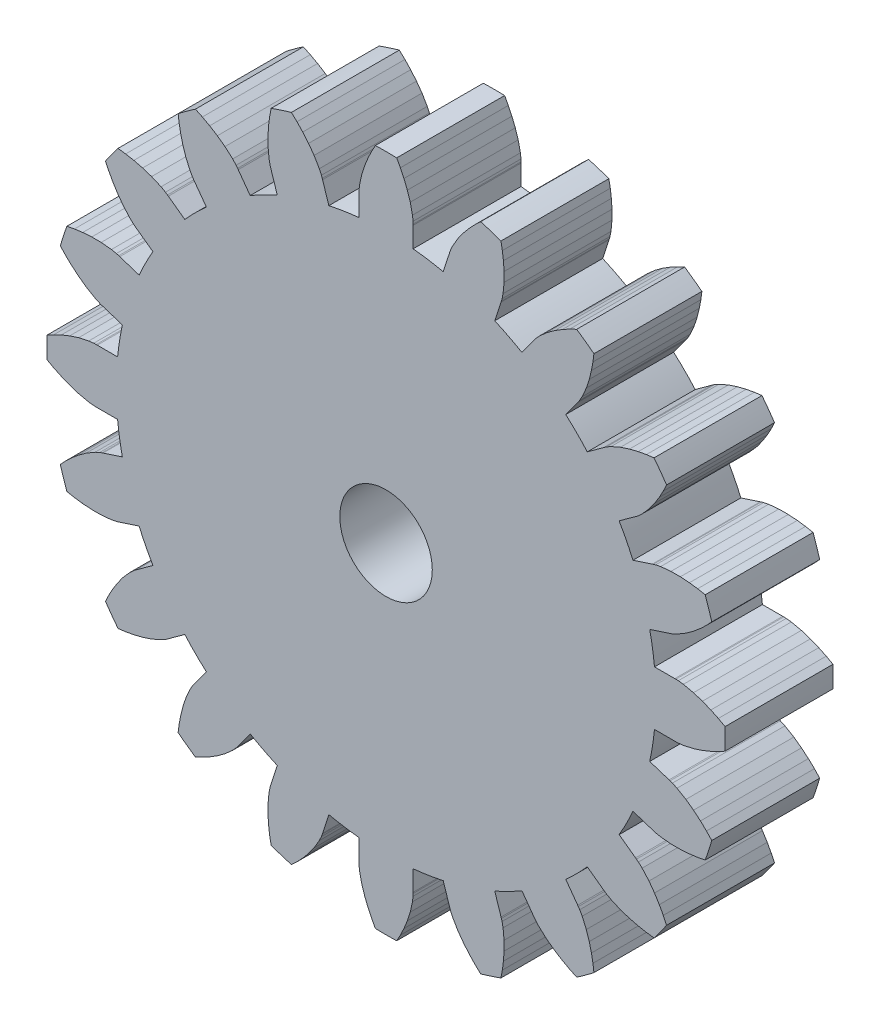
from build123d import *

# Parameters (mm, degrees)
ESQUISSE1_R        = 1.5
BOSS_EXTRU_1_DEPTH = 3.5


with BuildPart() as part:
    # Esquisse1 → Boss.-Extru.1 (new body)
    with BuildSketch(Plane.XY.offset(10)):
        with BuildLine():
            Line((10.391944356, 2.887552219), (10.563205564, 3.068988142))
            ThreePointArc((10.563205564, 3.068988142), (10.461621679, 3.399186938), (10.349718786, 3.726032885))
            Line((10.349718786, 3.726032885), (10.104520198, 3.772152817))
            Line((10.104520198, 3.772152817), (9.837219071, 3.807097852))
            Line((9.837219071, 3.807097852), (9.544179746, 3.827948471))
            Line((9.544179746, 3.827948471), (9.238485434, 3.827582381))
            Line((9.238485434, 3.827582381), (8.905478411, 3.795081802))
            Line((8.905478411, 3.795081802), (8.744253499, 3.762531781))
            Line((8.744253499, 3.762531781), (8.667570956, 3.740873836))
            Line((8.667570956, 3.740873836), (8.6348822, 3.729525456))
            Line((8.6348822, 3.729525456), (8.008304172, 3.52555872))
            ThreePointArc((8.008304172, 3.52555872), (7.796307087, 3.972416873), (7.559400007, 4.40658275))
            Line((7.559400007, 4.40658275), (8.092705887, 4.793606383))
            Line((8.092705887, 4.793606383), (8.121100889, 4.813381732))
            Line((8.121100889, 4.813381732), (8.183695402, 4.862688991))
            Line((8.183695402, 4.862688991), (8.304794548, 4.973990263))
            Line((8.304794548, 4.973990263), (8.526824685, 5.224295243))
            Line((8.526824685, 5.224295243), (8.706803467, 5.471391954))
            Line((8.706803467, 5.471391954), (8.862179155, 5.720721434))
            Line((8.862179155, 5.720721434), (8.991023689, 5.957512765))
            Line((8.991023689, 5.957512765), (9.097835993, 6.182991205))
            ThreePointArc((9.097835993, 6.182991205), (8.899186938, 6.465637775), (8.69176001, 6.741906847))
            Line((8.69176001, 6.741906847), (8.444310453, 6.709998979))
            Line((8.444310453, 6.709998979), (8.179293364, 6.660633091))
            Line((8.179293364, 6.660633091), (7.894153209, 6.589909076))
            Line((7.894153209, 6.589909076), (7.60353377, 6.495096166))
            Line((7.60353377, 6.495096166), (7.296868502, 6.36128145))
            Line((7.296868502, 6.36128145), (7.153593008, 6.280503303))
            Line((7.153593008, 6.280503303), (7.087356249, 6.236209164))
            Line((7.087356249, 6.236209164), (7.059774237, 6.215314832))
            Line((7.059774237, 6.215314832), (6.526892308, 5.82770768))
            ThreePointArc((6.526892308, 5.82770768), (6.187184335, 6.187184335), (5.82770768, 6.526892308))
            Line((5.82770768, 6.526892308), (6.215314832, 7.059774237))
            Line((6.215314832, 7.059774237), (6.236209164, 7.087356249))
            Line((6.236209164, 7.087356249), (6.280503303, 7.153593008))
            Line((6.280503303, 7.153593008), (6.36128145, 7.296868502))
            Line((6.36128145, 7.296868502), (6.495096166, 7.60353377))
            Line((6.495096166, 7.60353377), (6.589909076, 7.894153209))
            Line((6.589909076, 7.894153209), (6.660633091, 8.179293364))
            Line((6.660633091, 8.179293364), (6.709998979, 8.444310453))
            Line((6.709998979, 8.444310453), (6.741906847, 8.69176001))
            ThreePointArc((6.741906847, 8.69176001), (6.465637775, 8.899186938), (6.182991205, 9.097835993))
            Line((6.182991205, 9.097835993), (5.957512765, 8.991023689))
            Line((5.957512765, 8.991023689), (5.720721434, 8.862179155))
            Line((5.720721434, 8.862179155), (5.471391954, 8.706803467))
            Line((5.471391954, 8.706803467), (5.224295243, 8.526824685))
            Line((5.224295243, 8.526824685), (4.973990263, 8.304794548))
            Line((4.973990263, 8.304794548), (4.862688991, 8.183695402))
            Line((4.862688991, 8.183695402), (4.813381732, 8.121100889))
            Line((4.813381732, 8.121100889), (4.793606383, 8.092705887))
            Line((4.793606383, 8.092705887), (4.40658275, 7.559400007))
            ThreePointArc((4.40658275, 7.559400007), (3.972416873, 7.796307087), (3.52555872, 8.008304172))
            Line((3.52555872, 8.008304172), (3.729525456, 8.6348822))
            Line((3.729525456, 8.6348822), (3.740873836, 8.667570956))
            Line((3.740873836, 8.667570956), (3.762531781, 8.744253499))
            Line((3.762531781, 8.744253499), (3.795081802, 8.905478411))
            Line((3.795081802, 8.905478411), (3.827582381, 9.238485434))
            Line((3.827582381, 9.238485434), (3.827948471, 9.544179746))
            Line((3.827948471, 9.544179746), (3.807097852, 9.837219071))
            Line((3.807097852, 9.837219071), (3.772152817, 10.104520198))
            Line((3.772152817, 10.104520198), (3.726032885, 10.349718786))
            ThreePointArc((3.726032885, 10.349718786), (3.399186938, 10.461621679), (3.068988142, 10.563205564))
            Line((3.068988142, 10.563205564), (2.887552219, 10.391944356))
            Line((2.887552219, 10.391944356), (2.702165432, 10.196233377))
            Line((2.702165432, 10.196233377), (2.513052733, 9.97141527))
            Line((2.513052733, 9.97141527), (2.333666298, 9.723888194))
            Line((2.333666298, 9.723888194), (2.164223202, 9.435376492))
            Line((2.164223202, 9.435376492), (2.095791096, 9.285810376))
            Line((2.095791096, 9.285810376), (2.068239874, 9.211042675))
            Line((2.068239874, 9.211042675), (2.058206937, 9.177926505))
            Line((2.058206937, 9.177926505), (1.854926169, 8.551125593))
            ThreePointArc((1.854926169, 8.551125593), (1.368801569, 8.64227298), (0.878303509, 8.705807426))
            Line((0.878303509, 8.705807426), (0.878664144, 9.364747731))
            Line((0.878664144, 9.364747731), (0.879355713, 9.399343428))
            Line((0.879355713, 9.399343428), (0.876257434, 9.478965532))
            Line((0.876257434, 9.478965532), (0.857393106, 9.642358046))
            Line((0.857393106, 9.642358046), (0.785398163, 9.969109776))
            Line((0.785398163, 9.969109776), (0.691281599, 10.259955471))
            Line((0.691281599, 10.259955471), (0.58089735, 10.532209235))
            Line((0.58089735, 10.532209235), (0.465062056, 10.775629104))
            Line((0.465062056, 10.775629104), (0.345428864, 10.994574976))
            ThreePointArc((0.345428864, 10.994574976), (0, 11), (-0.345428864, 10.994574976))
            Line((-0.345428864, 10.994574976), (-0.465062056, 10.775629104))
            Line((-0.465062056, 10.775629104), (-0.58089735, 10.532209235))
            Line((-0.58089735, 10.532209235), (-0.691281599, 10.259955471))
            Line((-0.691281599, 10.259955471), (-0.785398163, 9.969109776))
            Line((-0.785398163, 9.969109776), (-0.857393106, 9.642358046))
            Line((-0.857393106, 9.642358046), (-0.876257434, 9.478965532))
            Line((-0.876257434, 9.478965532), (-0.879355713, 9.399343428))
            Line((-0.879355713, 9.399343428), (-0.878664144, 9.364747731))
            Line((-0.878664144, 9.364747731), (-0.878303509, 8.705807426))
            ThreePointArc((-0.878303509, 8.705807426), (-1.368801569, 8.64227298), (-1.854926169, 8.551125593))
            Line((-1.854926169, 8.551125593), (-2.058206937, 9.177926505))
            Line((-2.058206937, 9.177926505), (-2.068239874, 9.211042675))
            Line((-2.068239874, 9.211042675), (-2.095791096, 9.285810376))
            Line((-2.095791096, 9.285810376), (-2.164223202, 9.435376492))
            Line((-2.164223202, 9.435376492), (-2.333666298, 9.723888194))
            Line((-2.333666298, 9.723888194), (-2.513052733, 9.97141527))
            Line((-2.513052733, 9.97141527), (-2.702165432, 10.196233377))
            Line((-2.702165432, 10.196233377), (-2.887552219, 10.391944356))
            Line((-2.887552219, 10.391944356), (-3.068988142, 10.563205564))
            ThreePointArc((-3.068988142, 10.563205564), (-3.399186938, 10.461621679), (-3.726032885, 10.349718786))
            Line((-3.726032885, 10.349718786), (-3.772152817, 10.104520198))
            Line((-3.772152817, 10.104520198), (-3.807097852, 9.837219071))
            Line((-3.807097852, 9.837219071), (-3.827948471, 9.544179746))
            Line((-3.827948471, 9.544179746), (-3.827582381, 9.238485434))
            Line((-3.827582381, 9.238485434), (-3.795081802, 8.905478411))
            Line((-3.795081802, 8.905478411), (-3.762531781, 8.744253499))
            Line((-3.762531781, 8.744253499), (-3.740873836, 8.667570956))
            Line((-3.740873836, 8.667570956), (-3.729525456, 8.6348822))
            Line((-3.729525456, 8.6348822), (-3.52555872, 8.008304172))
            ThreePointArc((-3.52555872, 8.008304172), (-3.972416873, 7.796307087), (-4.40658275, 7.559400007))
            Line((-4.40658275, 7.559400007), (-4.793606383, 8.092705887))
            Line((-4.793606383, 8.092705887), (-4.813381732, 8.121100889))
            Line((-4.813381732, 8.121100889), (-4.862688991, 8.183695402))
            Line((-4.862688991, 8.183695402), (-4.973990263, 8.304794548))
            Line((-4.973990263, 8.304794548), (-5.224295243, 8.526824685))
            Line((-5.224295243, 8.526824685), (-5.471391954, 8.706803467))
            Line((-5.471391954, 8.706803467), (-5.720721434, 8.862179155))
            Line((-5.720721434, 8.862179155), (-5.957512765, 8.991023689))
            Line((-5.957512765, 8.991023689), (-6.182991205, 9.097835993))
            ThreePointArc((-6.182991205, 9.097835993), (-6.465637775, 8.899186938), (-6.741906847, 8.69176001))
            Line((-6.741906847, 8.69176001), (-6.709998979, 8.444310453))
            Line((-6.709998979, 8.444310453), (-6.660633091, 8.179293364))
            Line((-6.660633091, 8.179293364), (-6.589909076, 7.894153209))
            Line((-6.589909076, 7.894153209), (-6.495096166, 7.60353377))
            Line((-6.495096166, 7.60353377), (-6.36128145, 7.296868502))
            Line((-6.36128145, 7.296868502), (-6.280503303, 7.153593008))
            Line((-6.280503303, 7.153593008), (-6.236209164, 7.087356249))
            Line((-6.236209164, 7.087356249), (-6.215314832, 7.059774237))
            Line((-6.215314832, 7.059774237), (-5.82770768, 6.526892308))
            ThreePointArc((-5.82770768, 6.526892308), (-6.187184335, 6.187184335), (-6.526892308, 5.82770768))
            Line((-6.526892308, 5.82770768), (-7.059774237, 6.215314832))
            Line((-7.059774237, 6.215314832), (-7.087356249, 6.236209164))
            Line((-7.087356249, 6.236209164), (-7.153593008, 6.280503303))
            Line((-7.153593008, 6.280503303), (-7.296868502, 6.36128145))
            Line((-7.296868502, 6.36128145), (-7.60353377, 6.495096166))
            Line((-7.60353377, 6.495096166), (-7.894153209, 6.589909076))
            Line((-7.894153209, 6.589909076), (-8.179293364, 6.660633091))
            Line((-8.179293364, 6.660633091), (-8.444310453, 6.709998979))
            Line((-8.444310453, 6.709998979), (-8.69176001, 6.741906847))
            ThreePointArc((-8.69176001, 6.741906847), (-8.899186938, 6.465637775), (-9.097835993, 6.182991205))
            Line((-9.097835993, 6.182991205), (-8.991023689, 5.957512765))
            Line((-8.991023689, 5.957512765), (-8.862179155, 5.720721434))
            Line((-8.862179155, 5.720721434), (-8.706803467, 5.471391954))
            Line((-8.706803467, 5.471391954), (-8.526824685, 5.224295243))
            Line((-8.526824685, 5.224295243), (-8.304794548, 4.973990263))
            Line((-8.304794548, 4.973990263), (-8.183695402, 4.862688991))
            Line((-8.183695402, 4.862688991), (-8.121100889, 4.813381732))
            Line((-8.121100889, 4.813381732), (-8.092705887, 4.793606383))
            Line((-8.092705887, 4.793606383), (-7.559400007, 4.40658275))
            ThreePointArc((-7.559400007, 4.40658275), (-7.796307087, 3.972416873), (-8.008304172, 3.52555872))
            Line((-8.008304172, 3.52555872), (-8.6348822, 3.729525456))
            Line((-8.6348822, 3.729525456), (-8.667570956, 3.740873836))
            Line((-8.667570956, 3.740873836), (-8.744253499, 3.762531781))
            Line((-8.744253499, 3.762531781), (-8.905478411, 3.795081802))
            Line((-8.905478411, 3.795081802), (-9.238485434, 3.827582381))
            Line((-9.238485434, 3.827582381), (-9.544179746, 3.827948471))
            Line((-9.544179746, 3.827948471), (-9.837219071, 3.807097852))
            Line((-9.837219071, 3.807097852), (-10.104520198, 3.772152817))
            Line((-10.104520198, 3.772152817), (-10.349718786, 3.726032885))
            ThreePointArc((-10.349718786, 3.726032885), (-10.461621679, 3.399186938), (-10.563205564, 3.068988142))
            Line((-10.563205564, 3.068988142), (-10.391944356, 2.887552219))
            Line((-10.391944356, 2.887552219), (-10.196233377, 2.702165432))
            Line((-10.196233377, 2.702165432), (-9.97141527, 2.513052733))
            Line((-9.97141527, 2.513052733), (-9.723888194, 2.333666298))
            Line((-9.723888194, 2.333666298), (-9.435376492, 2.164223202))
            Line((-9.435376492, 2.164223202), (-9.285810376, 2.095791096))
            Line((-9.285810376, 2.095791096), (-9.211042675, 2.068239874))
            Line((-9.211042675, 2.068239874), (-9.177926505, 2.058206937))
            Line((-9.177926505, 2.058206937), (-8.551125593, 1.854926169))
            ThreePointArc((-8.551125593, 1.854926169), (-8.64227298, 1.368801569), (-8.705807426, 0.878303509))
            Line((-8.705807426, 0.878303509), (-9.364747731, 0.878664144))
            Line((-9.364747731, 0.878664144), (-9.399343428, 0.879355713))
            Line((-9.399343428, 0.879355713), (-9.478965532, 0.876257434))
            Line((-9.478965532, 0.876257434), (-9.642358046, 0.857393106))
            Line((-9.642358046, 0.857393106), (-9.969109776, 0.785398163))
            Line((-9.969109776, 0.785398163), (-10.259955471, 0.691281599))
            Line((-10.259955471, 0.691281599), (-10.532209235, 0.58089735))
            Line((-10.532209235, 0.58089735), (-10.775629104, 0.465062056))
            Line((-10.775629104, 0.465062056), (-10.994574976, 0.345428864))
            ThreePointArc((-10.994574976, 0.345428864), (-11, 0), (-10.994574976, -0.345428864))
            Line((-10.994574976, -0.345428864), (-10.775629104, -0.465062056))
            Line((-10.775629104, -0.465062056), (-10.532209235, -0.58089735))
            Line((-10.532209235, -0.58089735), (-10.259955471, -0.691281599))
            Line((-10.259955471, -0.691281599), (-9.969109776, -0.785398163))
            Line((-9.969109776, -0.785398163), (-9.642358046, -0.857393106))
            Line((-9.642358046, -0.857393106), (-9.478965532, -0.876257434))
            Line((-9.478965532, -0.876257434), (-9.399343428, -0.879355713))
            Line((-9.399343428, -0.879355713), (-9.364747731, -0.878664144))
            Line((-9.364747731, -0.878664144), (-8.705807426, -0.878303509))
            ThreePointArc((-8.705807426, -0.878303509), (-8.64227298, -1.368801569), (-8.551125593, -1.854926169))
            Line((-8.551125593, -1.854926169), (-9.177926505, -2.058206937))
            Line((-9.177926505, -2.058206937), (-9.211042675, -2.068239874))
            Line((-9.211042675, -2.068239874), (-9.285810376, -2.095791096))
            Line((-9.285810376, -2.095791096), (-9.435376492, -2.164223202))
            Line((-9.435376492, -2.164223202), (-9.723888194, -2.333666298))
            Line((-9.723888194, -2.333666298), (-9.97141527, -2.513052733))
            Line((-9.97141527, -2.513052733), (-10.196233377, -2.702165432))
            Line((-10.196233377, -2.702165432), (-10.391944356, -2.887552219))
            Line((-10.391944356, -2.887552219), (-10.563205564, -3.068988142))
            ThreePointArc((-10.563205564, -3.068988142), (-10.461621679, -3.399186938), (-10.349718786, -3.726032885))
            Line((-10.349718786, -3.726032885), (-10.104520198, -3.772152817))
            Line((-10.104520198, -3.772152817), (-9.837219071, -3.807097852))
            Line((-9.837219071, -3.807097852), (-9.544179746, -3.827948471))
            Line((-9.544179746, -3.827948471), (-9.238485434, -3.827582381))
            Line((-9.238485434, -3.827582381), (-8.905478411, -3.795081802))
            Line((-8.905478411, -3.795081802), (-8.744253499, -3.762531781))
            Line((-8.744253499, -3.762531781), (-8.667570956, -3.740873836))
            Line((-8.667570956, -3.740873836), (-8.6348822, -3.729525456))
            Line((-8.6348822, -3.729525456), (-8.008304172, -3.52555872))
            ThreePointArc((-8.008304172, -3.52555872), (-7.796307087, -3.972416873), (-7.559400007, -4.40658275))
            Line((-7.559400007, -4.40658275), (-8.092705887, -4.793606383))
            Line((-8.092705887, -4.793606383), (-8.121100889, -4.813381732))
            Line((-8.121100889, -4.813381732), (-8.183695402, -4.862688991))
            Line((-8.183695402, -4.862688991), (-8.304794548, -4.973990263))
            Line((-8.304794548, -4.973990263), (-8.526824685, -5.224295243))
            Line((-8.526824685, -5.224295243), (-8.706803467, -5.471391954))
            Line((-8.706803467, -5.471391954), (-8.862179155, -5.720721434))
            Line((-8.862179155, -5.720721434), (-8.991023689, -5.957512765))
            Line((-8.991023689, -5.957512765), (-9.097835993, -6.182991205))
            ThreePointArc((-9.097835993, -6.182991205), (-8.899186938, -6.465637775), (-8.69176001, -6.741906847))
            Line((-8.69176001, -6.741906847), (-8.444310453, -6.709998979))
            Line((-8.444310453, -6.709998979), (-8.179293364, -6.660633091))
            Line((-8.179293364, -6.660633091), (-7.894153209, -6.589909076))
            Line((-7.894153209, -6.589909076), (-7.60353377, -6.495096166))
            Line((-7.60353377, -6.495096166), (-7.296868502, -6.36128145))
            Line((-7.296868502, -6.36128145), (-7.153593008, -6.280503303))
            Line((-7.153593008, -6.280503303), (-7.087356249, -6.236209164))
            Line((-7.087356249, -6.236209164), (-7.059774237, -6.215314832))
            Line((-7.059774237, -6.215314832), (-6.526892308, -5.82770768))
            ThreePointArc((-6.526892308, -5.82770768), (-6.187184335, -6.187184335), (-5.82770768, -6.526892308))
            Line((-5.82770768, -6.526892308), (-6.215314832, -7.059774237))
            Line((-6.215314832, -7.059774237), (-6.236209164, -7.087356249))
            Line((-6.236209164, -7.087356249), (-6.280503303, -7.153593008))
            Line((-6.280503303, -7.153593008), (-6.36128145, -7.296868502))
            Line((-6.36128145, -7.296868502), (-6.495096166, -7.60353377))
            Line((-6.495096166, -7.60353377), (-6.589909076, -7.894153209))
            Line((-6.589909076, -7.894153209), (-6.660633091, -8.179293364))
            Line((-6.660633091, -8.179293364), (-6.709998979, -8.444310453))
            Line((-6.709998979, -8.444310453), (-6.741906847, -8.69176001))
            ThreePointArc((-6.741906847, -8.69176001), (-6.465637775, -8.899186938), (-6.182991205, -9.097835993))
            Line((-6.182991205, -9.097835993), (-5.957512765, -8.991023689))
            Line((-5.957512765, -8.991023689), (-5.720721434, -8.862179155))
            Line((-5.720721434, -8.862179155), (-5.471391954, -8.706803467))
            Line((-5.471391954, -8.706803467), (-5.224295243, -8.526824685))
            Line((-5.224295243, -8.526824685), (-4.973990263, -8.304794548))
            Line((-4.973990263, -8.304794548), (-4.862688991, -8.183695402))
            Line((-4.862688991, -8.183695402), (-4.813381732, -8.121100889))
            Line((-4.813381732, -8.121100889), (-4.793606383, -8.092705887))
            Line((-4.793606383, -8.092705887), (-4.40658275, -7.559400007))
            ThreePointArc((-4.40658275, -7.559400007), (-3.972416873, -7.796307087), (-3.52555872, -8.008304172))
            Line((-3.52555872, -8.008304172), (-3.729525456, -8.6348822))
            Line((-3.729525456, -8.6348822), (-3.740873836, -8.667570956))
            Line((-3.740873836, -8.667570956), (-3.762531781, -8.744253499))
            Line((-3.762531781, -8.744253499), (-3.795081802, -8.905478411))
            Line((-3.795081802, -8.905478411), (-3.827582381, -9.238485434))
            Line((-3.827582381, -9.238485434), (-3.827948471, -9.544179746))
            Line((-3.827948471, -9.544179746), (-3.807097852, -9.837219071))
            Line((-3.807097852, -9.837219071), (-3.772152817, -10.104520198))
            Line((-3.772152817, -10.104520198), (-3.726032885, -10.349718786))
            ThreePointArc((-3.726032885, -10.349718786), (-3.399186938, -10.461621679), (-3.068988142, -10.563205564))
            Line((-3.068988142, -10.563205564), (-2.887552219, -10.391944356))
            Line((-2.887552219, -10.391944356), (-2.702165432, -10.196233377))
            Line((-2.702165432, -10.196233377), (-2.513052733, -9.97141527))
            Line((-2.513052733, -9.97141527), (-2.333666298, -9.723888194))
            Line((-2.333666298, -9.723888194), (-2.164223202, -9.435376492))
            Line((-2.164223202, -9.435376492), (-2.095791096, -9.285810376))
            Line((-2.095791096, -9.285810376), (-2.068239874, -9.211042675))
            Line((-2.068239874, -9.211042675), (-2.058206937, -9.177926505))
            Line((-2.058206937, -9.177926505), (-1.854926169, -8.551125593))
            ThreePointArc((-1.854926169, -8.551125593), (-1.368801569, -8.64227298), (-0.878303509, -8.705807426))
            Line((-0.878303509, -8.705807426), (-0.878664144, -9.364747731))
            Line((-0.878664144, -9.364747731), (-0.879355713, -9.399343428))
            Line((-0.879355713, -9.399343428), (-0.876257434, -9.478965532))
            Line((-0.876257434, -9.478965532), (-0.857393106, -9.642358046))
            Line((-0.857393106, -9.642358046), (-0.785398163, -9.969109776))
            Line((-0.785398163, -9.969109776), (-0.691281599, -10.259955471))
            Line((-0.691281599, -10.259955471), (-0.58089735, -10.532209235))
            Line((-0.58089735, -10.532209235), (-0.465062056, -10.775629104))
            Line((-0.465062056, -10.775629104), (-0.345428864, -10.994574976))
            ThreePointArc((-0.345428864, -10.994574976), (0, -11), (0.345428864, -10.994574976))
            Line((0.345428864, -10.994574976), (0.465062056, -10.775629104))
            Line((0.465062056, -10.775629104), (0.58089735, -10.532209235))
            Line((0.58089735, -10.532209235), (0.691281599, -10.259955471))
            Line((0.691281599, -10.259955471), (0.785398163, -9.969109776))
            Line((0.785398163, -9.969109776), (0.857393106, -9.642358046))
            Line((0.857393106, -9.642358046), (0.876257434, -9.478965532))
            Line((0.876257434, -9.478965532), (0.879355713, -9.399343428))
            Line((0.879355713, -9.399343428), (0.878664144, -9.364747731))
            Line((0.878664144, -9.364747731), (0.878303509, -8.705807426))
            ThreePointArc((0.878303509, -8.705807426), (1.368801569, -8.64227298), (1.854926169, -8.551125593))
            Line((1.854926169, -8.551125593), (2.058206937, -9.177926505))
            Line((2.058206937, -9.177926505), (2.068239874, -9.211042675))
            Line((2.068239874, -9.211042675), (2.095791096, -9.285810376))
            Line((2.095791096, -9.285810376), (2.164223202, -9.435376492))
            Line((2.164223202, -9.435376492), (2.333666298, -9.723888194))
            Line((2.333666298, -9.723888194), (2.513052733, -9.97141527))
            Line((2.513052733, -9.97141527), (2.702165432, -10.196233377))
            Line((2.702165432, -10.196233377), (2.887552219, -10.391944356))
            Line((2.887552219, -10.391944356), (3.068988142, -10.563205564))
            ThreePointArc((3.068988142, -10.563205564), (3.399186938, -10.461621679), (3.726032885, -10.349718786))
            Line((3.726032885, -10.349718786), (3.772152817, -10.104520198))
            Line((3.772152817, -10.104520198), (3.807097852, -9.837219071))
            Line((3.807097852, -9.837219071), (3.827948471, -9.544179746))
            Line((3.827948471, -9.544179746), (3.827582381, -9.238485434))
            Line((3.827582381, -9.238485434), (3.795081802, -8.905478411))
            Line((3.795081802, -8.905478411), (3.762531781, -8.744253499))
            Line((3.762531781, -8.744253499), (3.740873836, -8.667570956))
            Line((3.740873836, -8.667570956), (3.729525456, -8.6348822))
            Line((3.729525456, -8.6348822), (3.52555872, -8.008304172))
            ThreePointArc((3.52555872, -8.008304172), (3.972416873, -7.796307087), (4.40658275, -7.559400007))
            Line((4.40658275, -7.559400007), (4.793606383, -8.092705887))
            Line((4.793606383, -8.092705887), (4.813381732, -8.121100889))
            Line((4.813381732, -8.121100889), (4.862688991, -8.183695402))
            Line((4.862688991, -8.183695402), (4.973990263, -8.304794548))
            Line((4.973990263, -8.304794548), (5.224295243, -8.526824685))
            Line((5.224295243, -8.526824685), (5.471391954, -8.706803467))
            Line((5.471391954, -8.706803467), (5.720721434, -8.862179155))
            Line((5.720721434, -8.862179155), (5.957512765, -8.991023689))
            Line((5.957512765, -8.991023689), (6.182991205, -9.097835993))
            ThreePointArc((6.182991205, -9.097835993), (6.465637775, -8.899186938), (6.741906847, -8.69176001))
            Line((6.741906847, -8.69176001), (6.709998979, -8.444310453))
            Line((6.709998979, -8.444310453), (6.660633091, -8.179293364))
            Line((6.660633091, -8.179293364), (6.589909076, -7.894153209))
            Line((6.589909076, -7.894153209), (6.495096166, -7.60353377))
            Line((6.495096166, -7.60353377), (6.36128145, -7.296868502))
            Line((6.36128145, -7.296868502), (6.280503303, -7.153593008))
            Line((6.280503303, -7.153593008), (6.236209164, -7.087356249))
            Line((6.236209164, -7.087356249), (6.215314832, -7.059774237))
            Line((6.215314832, -7.059774237), (5.82770768, -6.526892308))
            ThreePointArc((5.82770768, -6.526892308), (6.187184335, -6.187184335), (6.526892308, -5.82770768))
            Line((6.526892308, -5.82770768), (7.059774237, -6.215314832))
            Line((7.059774237, -6.215314832), (7.087356249, -6.236209164))
            Line((7.087356249, -6.236209164), (7.153593008, -6.280503303))
            Line((7.153593008, -6.280503303), (7.296868502, -6.36128145))
            Line((7.296868502, -6.36128145), (7.60353377, -6.495096166))
            Line((7.60353377, -6.495096166), (7.894153209, -6.589909076))
            Line((7.894153209, -6.589909076), (8.179293364, -6.660633091))
            Line((8.179293364, -6.660633091), (8.444310453, -6.709998979))
            Line((8.444310453, -6.709998979), (8.69176001, -6.741906847))
            ThreePointArc((8.69176001, -6.741906847), (8.899186938, -6.465637775), (9.097835993, -6.182991205))
            Line((9.097835993, -6.182991205), (8.991023689, -5.957512765))
            Line((8.991023689, -5.957512765), (8.862179155, -5.720721434))
            Line((8.862179155, -5.720721434), (8.706803467, -5.471391954))
            Line((8.706803467, -5.471391954), (8.526824685, -5.224295243))
            Line((8.526824685, -5.224295243), (8.304794548, -4.973990263))
            Line((8.304794548, -4.973990263), (8.183695402, -4.862688991))
            Line((8.183695402, -4.862688991), (8.121100889, -4.813381732))
            Line((8.121100889, -4.813381732), (8.092705887, -4.793606383))
            Line((8.092705887, -4.793606383), (7.559400007, -4.40658275))
            ThreePointArc((7.559400007, -4.40658275), (7.796307087, -3.972416873), (8.008304172, -3.52555872))
            Line((8.008304172, -3.52555872), (8.6348822, -3.729525456))
            Line((8.6348822, -3.729525456), (8.667570956, -3.740873836))
            Line((8.667570956, -3.740873836), (8.744253499, -3.762531781))
            Line((8.744253499, -3.762531781), (8.905478411, -3.795081802))
            Line((8.905478411, -3.795081802), (9.238485434, -3.827582381))
            Line((9.238485434, -3.827582381), (9.544179746, -3.827948471))
            Line((9.544179746, -3.827948471), (9.837219071, -3.807097852))
            Line((9.837219071, -3.807097852), (10.104520198, -3.772152817))
            Line((10.104520198, -3.772152817), (10.349718786, -3.726032885))
            ThreePointArc((10.349718786, -3.726032885), (10.461621679, -3.399186938), (10.563205564, -3.068988142))
            Line((10.563205564, -3.068988142), (10.391944356, -2.887552219))
            Line((10.391944356, -2.887552219), (10.196233377, -2.702165432))
            Line((10.196233377, -2.702165432), (9.97141527, -2.513052733))
            Line((9.97141527, -2.513052733), (9.723888194, -2.333666298))
            Line((9.723888194, -2.333666298), (9.435376492, -2.164223202))
            Line((9.435376492, -2.164223202), (9.285810376, -2.095791096))
            Line((9.285810376, -2.095791096), (9.211042675, -2.068239874))
            Line((9.211042675, -2.068239874), (9.177926505, -2.058206937))
            Line((9.177926505, -2.058206937), (8.551125593, -1.854926169))
            ThreePointArc((8.551125593, -1.854926169), (8.64227298, -1.368801569), (8.705807426, -0.878303509))
            Line((8.705807426, -0.878303509), (9.364747731, -0.878664144))
            Line((9.364747731, -0.878664144), (9.399343428, -0.879355713))
            Line((9.399343428, -0.879355713), (9.478965532, -0.876257434))
            Line((9.478965532, -0.876257434), (9.642358046, -0.857393106))
            Line((9.642358046, -0.857393106), (9.969109776, -0.785398163))
            Line((9.969109776, -0.785398163), (10.259955471, -0.691281599))
            Line((10.259955471, -0.691281599), (10.532209235, -0.58089735))
            Line((10.532209235, -0.58089735), (10.775629104, -0.465062056))
            Line((10.775629104, -0.465062056), (10.994574976, -0.345428864))
            ThreePointArc((10.994574976, -0.345428864), (11, 0), (10.994574976, 0.345428864))
            Line((10.994574976, 0.345428864), (10.775629104, 0.465062056))
            Line((10.775629104, 0.465062056), (10.532209235, 0.58089735))
            Line((10.532209235, 0.58089735), (10.259955471, 0.691281599))
            Line((10.259955471, 0.691281599), (9.969109776, 0.785398163))
            Line((9.969109776, 0.785398163), (9.642358046, 0.857393106))
            Line((9.642358046, 0.857393106), (9.478965532, 0.876257434))
            Line((9.478965532, 0.876257434), (9.399343428, 0.879355713))
            Line((9.399343428, 0.879355713), (9.364747731, 0.878664144))
            Line((9.364747731, 0.878664144), (8.705807426, 0.878303509))
            ThreePointArc((8.705807426, 0.878303509), (8.64227298, 1.368801569), (8.551125593, 1.854926169))
            Line((8.551125593, 1.854926169), (9.177926505, 2.058206937))
            Line((9.177926505, 2.058206937), (9.211042675, 2.068239874))
            Line((9.211042675, 2.068239874), (9.285810376, 2.095791096))
            Line((9.285810376, 2.095791096), (9.435376492, 2.164223202))
            Line((9.435376492, 2.164223202), (9.723888194, 2.333666298))
            Line((9.723888194, 2.333666298), (9.97141527, 2.513052733))
            Line((9.97141527, 2.513052733), (10.196233377, 2.702165432))
            Line((10.196233377, 2.702165432), (10.391944356, 2.887552219))
        make_face()
        Circle(ESQUISSE1_R, mode=Mode.SUBTRACT)
    extrude(amount=-BOSS_EXTRU_1_DEPTH)


solid = part.part
